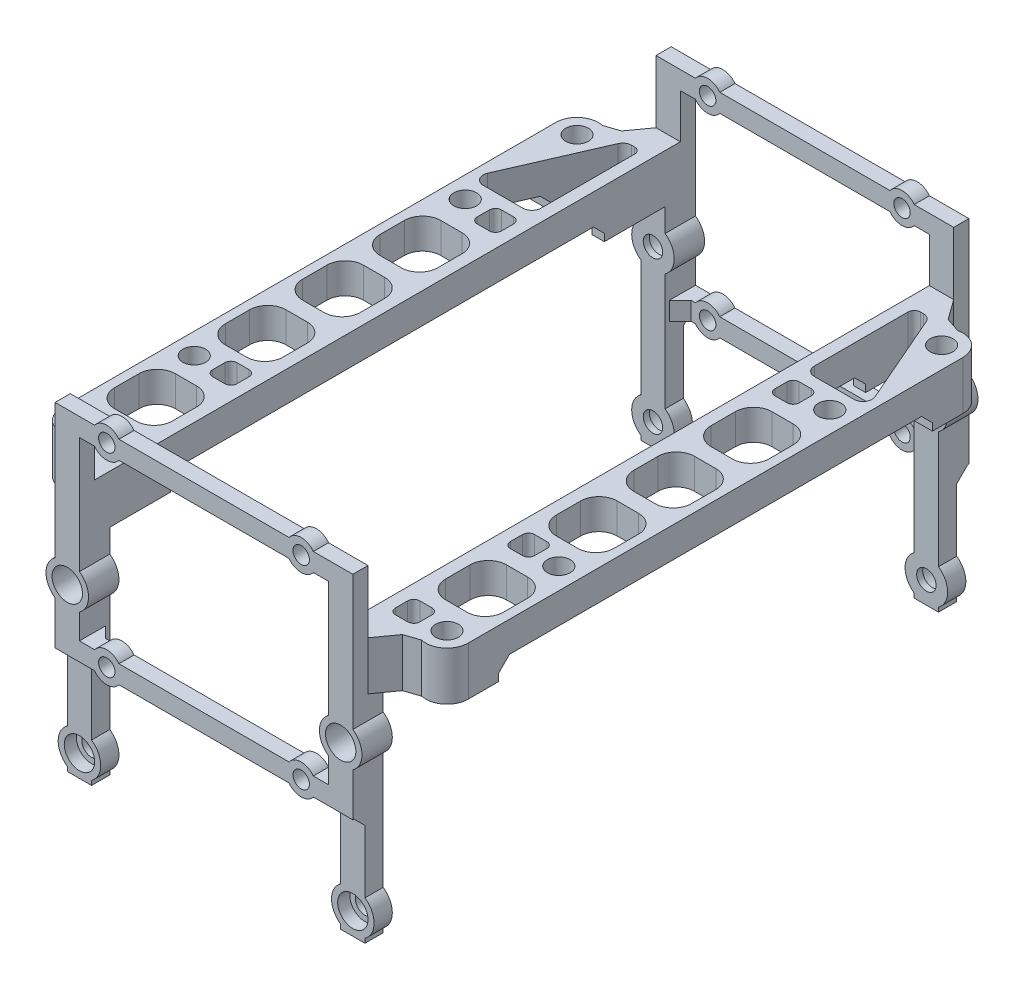
from build123d import *

# Parameters (mm, degrees)
BOSS_EXTRUDE1_DEPTH      = 4
SKETCH2_R                = 1.6
CUT_EXTRUDE1_DEPTH       = 49.7
CUT_EXTRUDE1_DEPTH_BACK  = 1
SKETCH3_R                = 1.35
SKETCH3_R_2              = 2.5
BOSS_EXTRUDE2_DEPTH      = 2
BOSS_EXTRUDE2_DEPTH_BACK = 0.5
BOSS_EXTRUDE3_DEPTH      = 8
SKETCH10_R               = 3.5
SKETCH10_R_2             = 1.6
BOSS_EXTRUDE5_DEPTH      = 3
SKETCH11_R               = 2.5
CUT_EXTRUDE4_DEPTH       = 2
SKETCH8_R                = 1.875
CUT_EXTRUDE3_DEPTH       = 44.3
CHAMFER1_SIZE            = 2.5
SKETCH12_R               = 3
CUT_EXTRUDE7_DEPTH       = 4.5
SKETCH13_W               = 71.4
SKETCH13_H               = 7.385436
CUT_EXTRUDE8_DEPTH       = 68
CHAMFER2_SIZE            = 1.8
CHAMFER3_SIZE            = 1.8
CHAMFER4_SIZE            = 1.8


with BuildPart() as part:
    # Sketch1 → Boss-Extrude1 (new body)
    with BuildSketch(Plane(origin=(0, 0, 0), x_dir=(0, 0, -1), z_dir=(1, 0, 0))):
        Polygon((91.4, 35.3), (45.7, 35.3), (45.7, 43.3), (94.4, 43.3), (94.4, 0), (91.4, 0), align=None)
    extrude(amount=BOSS_EXTRUDE1_DEPTH)

    # Sketch2 → Cut-Extrude1 (cut, two sides)
    with BuildSketch(Plane.XY.offset(-94.4)) as cut_extrude1_sk:
        with Locations((2, 28.6)):
            Circle(SKETCH2_R)
        with Locations((2, 3.6)):
            Circle(SKETCH2_R)
    extrude(amount=CUT_EXTRUDE1_DEPTH, mode=Mode.SUBTRACT)
    extrude(cut_extrude1_sk.sketch, amount=-CUT_EXTRUDE1_DEPTH_BACK, mode=Mode.SUBTRACT)

    # Sketch3 → Boss-Extrude2 (add, two sides)
    with BuildSketch(Plane(origin=(0, 0, -94.4), x_dir=(-1, 0, 0), z_dir=(0, 0, -1))) as boss_extrude2_sk:
        with BuildLine():
            Line((20.5, 53.6), (6.5, 53.6))
            ThreePointArc((6.5, 53.6), (4.5, 54.6), (2.5, 53.6))
            Line((2.5, 53.6), (-4, 53.6))
            Line((-4, 53.6), (-4, 31.472281))
            ThreePointArc((-4, 31.472281), (-5.5, 28.6), (-4, 25.727719))
            Line((-4, 25.727719), (-4, 18.6))
            Line((-4, 18.6), (2.5, 18.6))
            ThreePointArc((2.5, 18.6), (4.5, 17.6), (6.5, 18.6))
            Line((6.5, 18.6), (20.5, 18.6))
            Line((20.5, 18.6), (20.5, 21.6))
            Line((20.5, 21.6), (6.5, 21.6))
            ThreePointArc((6.5, 21.6), (4.5, 22.6), (2.5, 21.6))
            Line((2.5, 21.6), (0, 21.6))
            Line((0, 21.6), (0, 25.727719))
            ThreePointArc((0, 25.727719), (1.5, 28.6), (0, 31.472281))
            Line((0, 31.472281), (0, 50.6))
            Line((0, 50.6), (2.5, 50.6))
            ThreePointArc((2.5, 50.6), (4.5, 49.6), (6.5, 50.6))
            Line((6.5, 50.6), (20.5, 50.6))
            Line((20.5, 50.6), (20.5, 53.6))
        make_face()
        with Locations((4.5, 52.1)):
            Circle(SKETCH3_R, mode=Mode.SUBTRACT)
        with Locations((-2, 28.6)):
            Circle(SKETCH3_R_2, mode=Mode.SUBTRACT)
        with Locations((4.5, 20.1)):
            Circle(SKETCH3_R, mode=Mode.SUBTRACT)
    extrude(amount=BOSS_EXTRUDE2_DEPTH)
    extrude(boss_extrude2_sk.sketch, amount=-BOSS_EXTRUDE2_DEPTH_BACK)

    # Sketch5 → Boss-Extrude3 (add)
    with BuildSketch(Plane(origin=(0, 43.3, 0), x_dir=(1, 0, 0), z_dir=(0, 1, 0))):
        with BuildLine():
            Line((4, 91.4), (8.746327, 89.817891))
            ThreePointArc((8.746327, 89.817891), (11.692276, 89.128356), (13, 86.4))
            Line((13, 86.4), (13, 45.7))
            Line((13, 45.7), (0, 45.7))
            Line((0, 45.7), (0, 91.4))
            Line((0, 91.4), (4, 91.4))
        make_face()
    extrude(amount=-BOSS_EXTRUDE3_DEPTH)

    # Sketch10 → Boss-Extrude5 (add)
    with BuildSketch(Plane(origin=(0, 0, -94.4), x_dir=(-1, 0, 0), z_dir=(0, 0, -1))):
        with Locations((-2, 28.6)):
            Circle(SKETCH10_R)
        with Locations((-2, 28.6)):
            Circle(SKETCH10_R_2, mode=Mode.SUBTRACT)
        with Locations((-2, 3.6)):
            Circle(SKETCH10_R)
        with Locations((-2, 3.6)):
            Circle(SKETCH10_R_2, mode=Mode.SUBTRACT)
    extrude(amount=-BOSS_EXTRUDE5_DEPTH)

    # Sketch11 → Cut-Extrude4 (cut)
    with BuildSketch(Plane(origin=(0, 0, -94.4), x_dir=(-1, 0, 0), z_dir=(0, 0, -1))):
        with Locations((-2, 28.6)):
            Circle(SKETCH11_R)
        with Locations((-2, 3.6)):
            Circle(SKETCH11_R)
    extrude(amount=-CUT_EXTRUDE4_DEPTH, mode=Mode.SUBTRACT)

    # Mirror4: part across plane


with BuildPart() as part_1:
    add(part.part)
    add(part.part.mirror(Plane(origin=(-20.5, 0, -96.4), x_dir=(0, 0, 1), z_dir=(-1, 0, 0))))

    # Mirror5: part across plane


with BuildPart() as part_2:
    add(part_1.part)
    add(part_1.part.mirror(Plane(origin=(4, 0, -45.7), x_dir=(1, 0, 0), z_dir=(0, 0, -1))))

    # Sketch8 → Cut-Extrude3 (cut, through all)
    with BuildSketch(Plane(origin=(0, 43.3, 0), x_dir=(1, 0, 0), z_dir=(0, 1, 0))):
        with Locations((9.5, 86.4)):
            Circle(SKETCH8_R)
        with Locations((9.5, 5)):
            Circle(SKETCH8_R)
        with Locations((9.5, 23.4)):
            Circle(SKETCH8_R)
        with Locations((9.5, 68)):
            Circle(SKETCH8_R)
        with Locations((-50.5, 68)):
            Circle(SKETCH8_R)
        with Locations((-50.5, 23.4)):
            Circle(SKETCH8_R)
        with Locations((-50.5, 5)):
            Circle(SKETCH8_R)
        with Locations((-50.5, 86.4)):
            Circle(SKETCH8_R)
        with BuildLine():
            Line((5, 50.241464), (8.5, 50.241464))
            ThreePointArc((8.5, 50.241464), (10.62132, 49.362784), (11.5, 47.241464))
            Line((11.5, 47.241464), (11.5, 43.241464))
            ThreePointArc((11.5, 43.241464), (10.62132, 41.120144), (8.5, 40.241464))
            Line((8.5, 40.241464), (5, 40.241464))
            ThreePointArc((5, 40.241464), (2.87868, 41.120144), (2, 43.241464))
            Line((2, 43.241464), (2, 47.241464))
            ThreePointArc((2, 47.241464), (2.87868, 49.362784), (5, 50.241464))
        make_face()
        with BuildLine():
            Line((5, 62.974937), (8.5, 62.974937))
            ThreePointArc((8.5, 62.974937), (10.62132, 62.096258), (11.5, 59.974937))
            Line((11.5, 59.974937), (11.5, 55.974937))
            ThreePointArc((11.5, 55.974937), (10.62132, 53.853617), (8.5, 52.974937))
            Line((8.5, 52.974937), (5, 52.974937))
            ThreePointArc((5, 52.974937), (2.87868, 53.853617), (2, 55.974937))
            Line((2, 55.974937), (2, 59.974937))
            ThreePointArc((2, 59.974937), (2.87868, 62.096258), (5, 62.974937))
        make_face()
        with BuildLine():
            Line((2, 88.4), (2, 72.974937))
            ThreePointArc((2, 72.974937), (2.43934, 71.914277), (3.5, 71.474937))
            Line((3.5, 71.474937), (10, 71.474937))
            ThreePointArc((10, 71.474937), (11.25467, 72.152865), (11.37524, 73.573866))
            Line((11.37524, 73.573866), (4.87524, 88.498929))
            ThreePointArc((4.87524, 88.498929), (4.322072, 89.15467), (3.5, 89.4))
            Line((3.5, 89.4), (3, 89.4))
            ThreePointArc((3, 89.4), (2.292893, 89.107107), (2, 88.4))
        make_face()
        with BuildLine():
            Line((3, 69.474937), (5, 69.474937))
            ThreePointArc((5, 69.474937), (5.707107, 69.182044), (6, 68.474937))
            Line((6, 68.474937), (6, 66.474937))
            ThreePointArc((6, 66.474937), (5.707107, 65.76783), (5, 65.474937))
            Line((5, 65.474937), (3, 65.474937))
            ThreePointArc((3, 65.474937), (2.292893, 65.76783), (2, 66.474937))
            Line((2, 66.474937), (2, 68.474937))
            ThreePointArc((2, 68.474937), (2.292893, 69.182044), (3, 69.474937))
        make_face()
        with BuildLine():
            Line((5, 37.507991), (8.5, 37.507991))
            ThreePointArc((8.5, 37.507991), (10.62132, 36.629311), (11.5, 34.507991))
            Line((11.5, 34.507991), (11.5, 30.507991))
            ThreePointArc((11.5, 30.507991), (10.62132, 28.38667), (8.5, 27.507991))
            Line((8.5, 27.507991), (5, 27.507991))
            ThreePointArc((5, 27.507991), (2.87868, 28.38667), (2, 30.507991))
            Line((2, 30.507991), (2, 34.507991))
            ThreePointArc((2, 34.507991), (2.87868, 36.629311), (5, 37.507991))
        make_face()
        with BuildLine():
            Line((6, 22.925063), (6, 24.925063))
            ThreePointArc((6, 24.925063), (5.707107, 25.63217), (5, 25.925063))
            Line((5, 25.925063), (3, 25.925063))
            ThreePointArc((3, 25.925063), (2.292893, 25.63217), (2, 24.925063))
            Line((2, 24.925063), (2, 22.925063))
            ThreePointArc((2, 22.925063), (2.292893, 22.217956), (3, 21.925063))
            Line((3, 21.925063), (5, 21.925063))
            ThreePointArc((5, 21.925063), (5.707107, 22.217956), (6, 22.925063))
        make_face()
        with BuildLine():
            Line((11.5, 12.292009), (11.5, 16.292009))
            ThreePointArc((11.5, 16.292009), (10.62132, 18.41333), (8.5, 19.292009))
            Line((8.5, 19.292009), (5, 19.292009))
            ThreePointArc((5, 19.292009), (2.87868, 18.41333), (2, 16.292009))
            Line((2, 16.292009), (2, 12.292009))
            ThreePointArc((2, 12.292009), (2.87868, 10.170689), (5, 9.292009))
            Line((5, 9.292009), (8.5, 9.292009))
            ThreePointArc((8.5, 9.292009), (10.62132, 10.170689), (11.5, 12.292009))
        make_face()
        with BuildLine():
            Line((-46, 9.292009), (-49.5, 9.292009))
            ThreePointArc((-49.5, 9.292009), (-51.62132, 10.170689), (-52.5, 12.292009))
            Line((-52.5, 12.292009), (-52.5, 16.292009))
            ThreePointArc((-52.5, 16.292009), (-51.62132, 18.41333), (-49.5, 19.292009))
            Line((-49.5, 19.292009), (-46, 19.292009))
            ThreePointArc((-46, 19.292009), (-43.87868, 18.41333), (-43, 16.292009))
            Line((-43, 16.292009), (-43, 12.292009))
            ThreePointArc((-43, 12.292009), (-43.87868, 10.170689), (-46, 9.292009))
        make_face()
        with BuildLine():
            Line((-44, 21.925063), (-46, 21.925063))
            ThreePointArc((-46, 21.925063), (-46.707107, 22.217956), (-47, 22.925063))
            Line((-47, 22.925063), (-47, 24.925063))
            ThreePointArc((-47, 24.925063), (-46.707107, 25.63217), (-46, 25.925063))
            Line((-46, 25.925063), (-44, 25.925063))
            ThreePointArc((-44, 25.925063), (-43.292893, 25.63217), (-43, 24.925063))
            Line((-43, 24.925063), (-43, 22.925063))
            ThreePointArc((-43, 22.925063), (-43.292893, 22.217956), (-44, 21.925063))
        make_face()
        with BuildLine():
            Line((-52.5, 34.507991), (-52.5, 30.507991))
            ThreePointArc((-52.5, 30.507991), (-51.62132, 28.38667), (-49.5, 27.507991))
            Line((-49.5, 27.507991), (-46, 27.507991))
            ThreePointArc((-46, 27.507991), (-43.87868, 28.38667), (-43, 30.507991))
            Line((-43, 30.507991), (-43, 34.507991))
            ThreePointArc((-43, 34.507991), (-43.87868, 36.629311), (-46, 37.507991))
            Line((-46, 37.507991), (-49.5, 37.507991))
            ThreePointArc((-49.5, 37.507991), (-51.62132, 36.629311), (-52.5, 34.507991))
        make_face()
        with BuildLine():
            Line((-52.5, 47.241464), (-52.5, 43.241464))
            ThreePointArc((-52.5, 43.241464), (-51.62132, 41.120144), (-49.5, 40.241464))
            Line((-49.5, 40.241464), (-46, 40.241464))
            ThreePointArc((-46, 40.241464), (-43.87868, 41.120144), (-43, 43.241464))
            Line((-43, 43.241464), (-43, 47.241464))
            ThreePointArc((-43, 47.241464), (-43.87868, 49.362784), (-46, 50.241464))
            Line((-46, 50.241464), (-49.5, 50.241464))
            ThreePointArc((-49.5, 50.241464), (-51.62132, 49.362784), (-52.5, 47.241464))
        make_face()
        with BuildLine():
            Line((-47, 68.474937), (-47, 66.474937))
            ThreePointArc((-47, 66.474937), (-46.707107, 65.76783), (-46, 65.474937))
            Line((-46, 65.474937), (-44, 65.474937))
            ThreePointArc((-44, 65.474937), (-43.292893, 65.76783), (-43, 66.474937))
            Line((-43, 66.474937), (-43, 68.474937))
            ThreePointArc((-43, 68.474937), (-43.292893, 69.182044), (-44, 69.474937))
            Line((-44, 69.474937), (-46, 69.474937))
            ThreePointArc((-46, 69.474937), (-46.707107, 69.182044), (-47, 68.474937))
        make_face()
        with BuildLine():
            Line((-52.5, 59.974937), (-52.5, 55.974937))
            ThreePointArc((-52.5, 55.974937), (-51.62132, 53.853617), (-49.5, 52.974937))
            Line((-49.5, 52.974937), (-46, 52.974937))
            ThreePointArc((-46, 52.974937), (-43.87868, 53.853617), (-43, 55.974937))
            Line((-43, 55.974937), (-43, 59.974937))
            ThreePointArc((-43, 59.974937), (-43.87868, 62.096258), (-46, 62.974937))
            Line((-46, 62.974937), (-49.5, 62.974937))
            ThreePointArc((-49.5, 62.974937), (-51.62132, 62.096258), (-52.5, 59.974937))
        make_face()
        with BuildLine():
            Line((-44.5, 89.4), (-44, 89.4))
            ThreePointArc((-44, 89.4), (-43.292893, 89.107107), (-43, 88.4))
            Line((-43, 88.4), (-43, 72.974937))
            ThreePointArc((-43, 72.974937), (-43.43934, 71.914277), (-44.5, 71.474937))
            Line((-44.5, 71.474937), (-51, 71.474937))
            ThreePointArc((-51, 71.474937), (-52.25467, 72.152865), (-52.37524, 73.573866))
            Line((-52.37524, 73.573866), (-45.87524, 88.498929))
            ThreePointArc((-45.87524, 88.498929), (-45.322072, 89.15467), (-44.5, 89.4))
        make_face()
        with BuildLine():
            Line((6, 3.969435), (6, 6.030565))
            ThreePointArc((6, 6.030565), (5.707107, 6.737672), (5, 7.030565))
            Line((5, 7.030565), (3, 7.030565))
            ThreePointArc((3, 7.030565), (2.292893, 6.737672), (2, 6.030565))
            Line((2, 6.030565), (2, 4.030565))
            ThreePointArc((2, 4.030565), (2.292893, 3.323458), (3, 3.030565))
            Line((3, 3.030565), (5, 3.030565))
            ThreePointArc((5, 3.030565), (5.686342, 3.301525), (6, 3.969435))
        make_face()
        with BuildLine():
            Line((-44, 3.030565), (-46, 3.030565))
            ThreePointArc((-46, 3.030565), (-46.686342, 3.301525), (-47, 3.969435))
            Line((-47, 3.969435), (-47, 6.030565))
            ThreePointArc((-47, 6.030565), (-46.707107, 6.737672), (-46, 7.030565))
            Line((-46, 7.030565), (-44, 7.030565))
            ThreePointArc((-44, 7.030565), (-43.292893, 6.737672), (-43, 6.030565))
            Line((-43, 6.030565), (-43, 4.030565))
            ThreePointArc((-43, 4.030565), (-43.292893, 3.323458), (-44, 3.030565))
        make_face()
    extrude(amount=-CUT_EXTRUDE3_DEPTH, mode=Mode.SUBTRACT)

    # Chamfer1
    chamfer1_edges = [part_2.edges().sort_by_distance(p)[0] for p in [
        (4, 39.3, -91.4),
        (-45, 39.3, -91.4),
        (4, 39.3, 0),
        (-45, 39.3, 0),
    ]]
    chamfer(chamfer1_edges, length=CHAMFER1_SIZE)

    # Sketch12 → Cut-Extrude7 (cut)
    with BuildSketch(Plane.XZ.offset(-35.3)):
        with Locations((9.5, -5)):
            Circle(SKETCH12_R)
        with Locations((9.5, -23.4)):
            Circle(SKETCH12_R)
        with Locations((9.5, -86.4)):
            Circle(SKETCH12_R)
        with Locations((9.5, -68)):
            Circle(SKETCH12_R)
        with Locations((-50.5, -86.4)):
            Circle(SKETCH12_R)
        with Locations((-50.5, -68)):
            Circle(SKETCH12_R)
        with Locations((-50.5, -23.4)):
            Circle(SKETCH12_R)
        with Locations((-50.5, -5)):
            Circle(SKETCH12_R)
    extrude(amount=-CUT_EXTRUDE7_DEPTH, mode=Mode.SUBTRACT)

    # Sketch13 → Cut-Extrude8 (cut, through all)
    with BuildSketch(Plane.ZY.offset(54)):
        with Locations((-45.7, 34.607282)):
            Rectangle(SKETCH13_W, SKETCH13_H)
    extrude(amount=-CUT_EXTRUDE8_DEPTH, mode=Mode.SUBTRACT)

    # Chamfer2
    chamfer2_edges = [part_2.edges().sort_by_distance(p)[0] for p in [
        (-43, 18.6, -94.4),
        (2, 18.6, 3),
        (-43, 18.6, 3),
        (2, 18.6, -94.4),
    ]]
    chamfer(chamfer2_edges, length=CHAMFER2_SIZE)

    # Chamfer3
    chamfer3_edges = [part_2.edges().sort_by_distance(p)[0] for p in [
        (-41, 20.1, -93.9),
        (0, 20.1, -93.9),
        (0, 20.1, 2.5),
        (-41, 20.1, 2.5),
    ]]
    chamfer(chamfer3_edges, length=CHAMFER3_SIZE)

    # Chamfer4
    chamfer4_edges = [part_2.edges().sort_by_distance(p)[0] for p in [
        (-42.532181, 38.3, -10),
        (-52.717819, 38.3, -10),
        (1.532181, 38.3, -10),
        (1, 38.3, -81.4),
        (10.483444, 38.3, -81.4),
        (-42, 38.3, -81.4),
        (-51.483444, 38.3, -81.4),
        (11.717819, 38.3, -10),
    ]]
    chamfer(chamfer4_edges, length=CHAMFER4_SIZE)


solid = part_2.part
